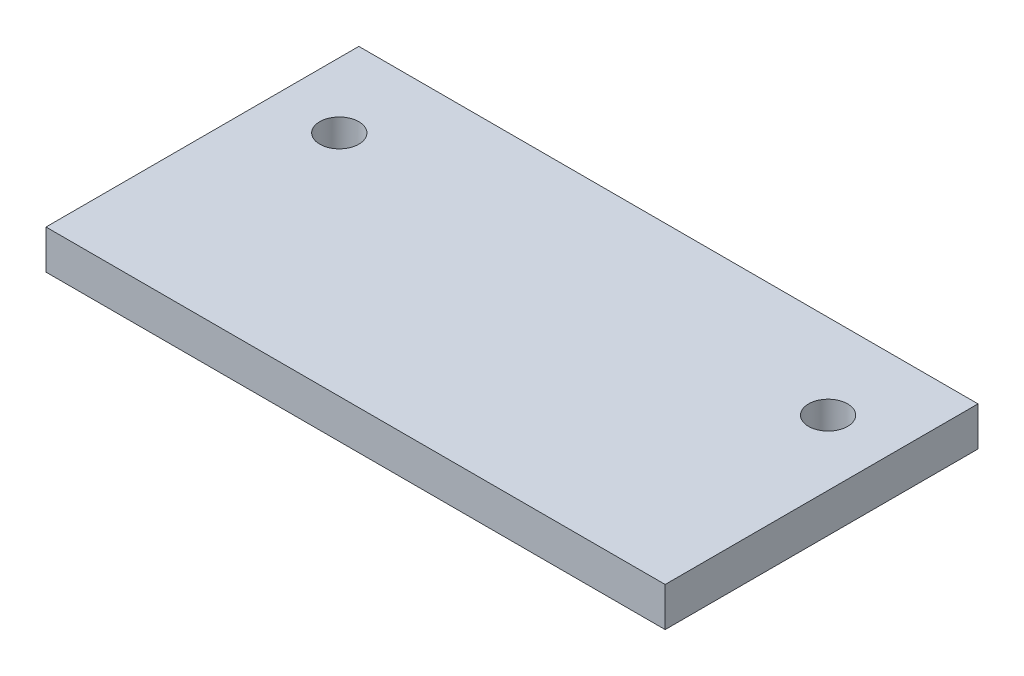
from build123d import *

# Parameters (mm, degrees)
SKETCH2_W                 = 47.5
SKETCH2_H                 = 35
BOSS_EXTRUDE1_DEPTH       = 3
F_3_0MM_DOWEL_HOLE1_D     = 3
F_3_0MM_DOWEL_HOLE1_DEPTH = 3
CUT_EXTRUDE1_REACH        = 5
SKETCH5_W                 = 47.5
SKETCH5_H                 = 11


with BuildPart() as part:
    # Sketch2 → Boss-Extrude1 (new body)
    with BuildSketch(Plane(origin=(0, 0, 0), x_dir=(1, 0, 0), z_dir=(0, 1, 0))):
        with Locations((23.75, 17.5)):
            Rectangle(SKETCH2_W, SKETCH2_H)
    extrude(amount=BOSS_EXTRUDE1_DEPTH)

    # Ø3.0mm Dowel Hole1
    with Locations(Plane(origin=(0, 3, 0), x_dir=(1, 0, 0), z_dir=(0, 1, 0))):
        with Locations((5, 17.5), (42.5, 17.5)):
            Hole(F_3_0MM_DOWEL_HOLE1_D / 2, depth=F_3_0MM_DOWEL_HOLE1_DEPTH)

    # Sketch5 → Cut-Extrude1 (cut, up to next)
    with BuildSketch(Plane(origin=(0, 3, 0), x_dir=(1, 0, 0), z_dir=(0, 1, 0)), mode=Mode.PRIVATE) as cut_extrude1_sk1:
        with Locations((23.75, 29.5)):
            Rectangle(SKETCH5_W, SKETCH5_H)
    cut_extrude1_tool1 = extrude(cut_extrude1_sk1.sketch, amount=-CUT_EXTRUDE1_REACH, mode=Mode.PRIVATE) & part.part
    add(cut_extrude1_tool1.solids().sort_by_distance((23.75, 3, -29.5))[0], mode=Mode.SUBTRACT)


solid = part.part
